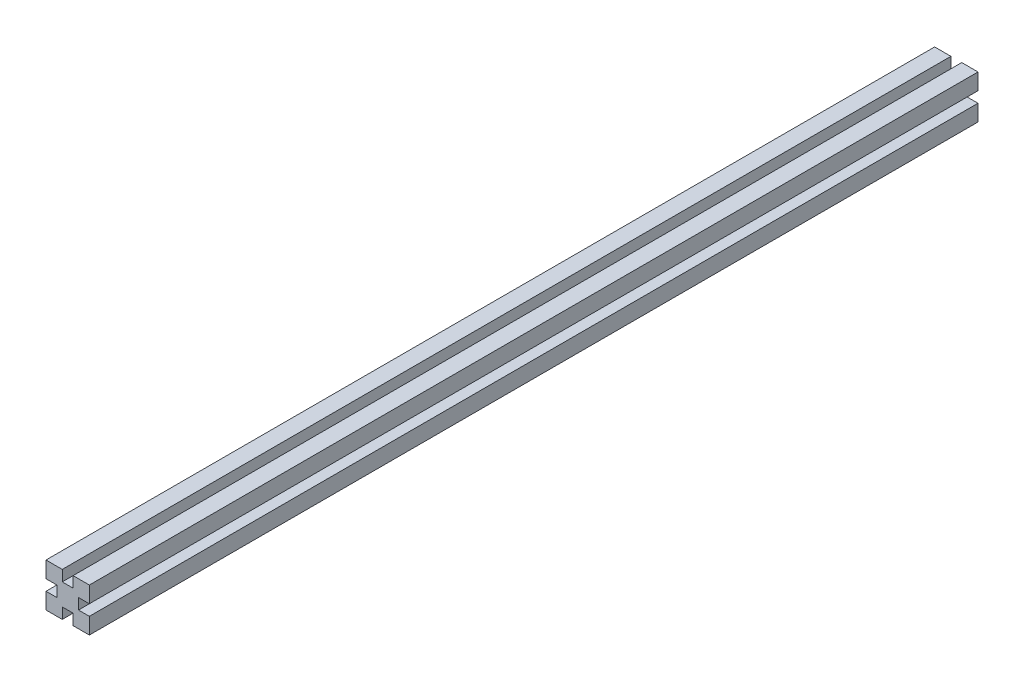
from build123d import *

# Parameters (mm, degrees)
SKETCH1_W           = 20
SKETCH1_H           = 20
BOSS_EXTRUDE1_DEPTH = 410
SKETCH1_3_W         = 5
SKETCH1_3_H         = 10
CUT_EXTRUDE1_DEPTH  = 645
CIRPATTERN1_COUNT   = 4


with BuildPart() as part:
    # Sketch1 → Boss-Extrude1 (new body)
    with BuildSketch(Plane.XY):
        Rectangle(SKETCH1_W, SKETCH1_H)
    extrude(amount=-BOSS_EXTRUDE1_DEPTH)

    # Sketch1_3 → Cut-Extrude1 (cut)
    with BuildSketch(Plane.XY):
        with Locations((0, 10)):
            Rectangle(SKETCH1_3_W, SKETCH1_3_H)
    cut_extrude1 = extrude(amount=-CUT_EXTRUDE1_DEPTH, mode=Mode.SUBTRACT)

    # CirPattern1: Cut-Extrude1 ×4 about axis
    cirpattern1_axis = Axis((0, 0, -256.415447735), (0, 0, -1))
    for i in range(1, CIRPATTERN1_COUNT):
        add(cut_extrude1.rotate(cirpattern1_axis, i * 360 / CIRPATTERN1_COUNT), mode=Mode.SUBTRACT)


solid = part.part
